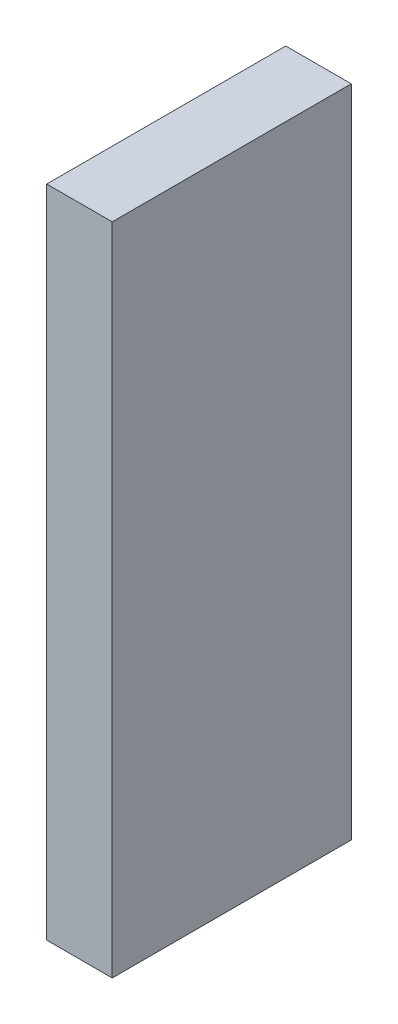
from build123d import *

# Parameters (mm, degrees)
SKETCH2_W           = 2.54
SKETCH2_H           = 25.4
BOSS_EXTRUDE1_DEPTH = 4.6355


with BuildPart() as part:
    # Sketch2 → Boss-Extrude1 (new body, symmetric)
    with BuildSketch(Plane.XY):
        Rectangle(SKETCH2_W, SKETCH2_H)
    extrude(amount=BOSS_EXTRUDE1_DEPTH, both=True)


solid = part.part
